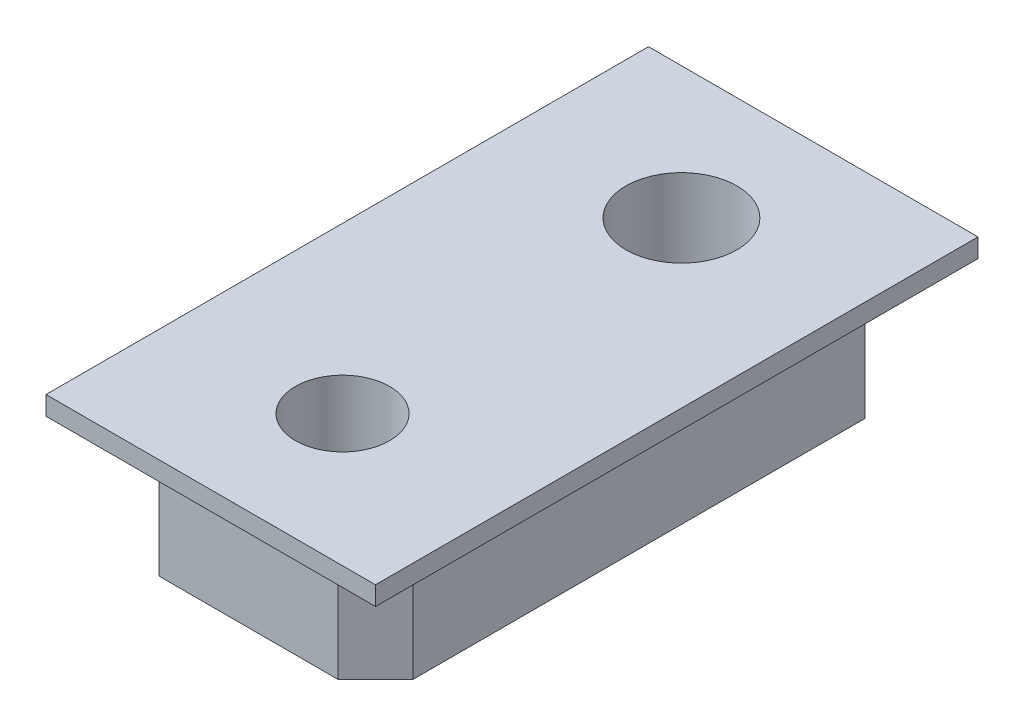
from build123d import *

# Parameters (mm, degrees)
SKETCH1_W             = 6.75
SKETCH1_H             = 3.175
EXTRUDE1_DEPTH        = 7
SKETCH6_W             = 8.75
SKETCH6_H             = 16
EXTRUDE2_DEPTH        = 0.5
F_4_CLEARANCE_HOLE1_D = 2.9464
SKETCH3_R             = 1.25
CUT_EXTRUDE1_DEPTH    = 4.675
CHAMFER1_SIZE         = 1


with BuildPart() as part:
    # Sketch1 → Extrude1 (new body, symmetric)
    with BuildSketch(Plane.XY):
        with Locations((0, 115.5875)):
            Rectangle(SKETCH1_W, SKETCH1_H)
    extrude(amount=EXTRUDE1_DEPTH, both=True)

    # Sketch6 → Extrude2 (add)
    with BuildSketch(Plane(origin=(0, 117.175, 0), x_dir=(1, 0, 0), z_dir=(0, 1, 0))):
        Rectangle(SKETCH6_W, SKETCH6_H)
    extrude(amount=EXTRUDE2_DEPTH)

    # 4 Clearance Hole1 (through all)
    with Locations(Plane(origin=(-0.355703292, 117.675, 3.885176073), x_dir=(-1, 0, 0), z_dir=(0, 1, 0))):
        with Locations((-0.355703292, -8.385176073)):
            Hole(F_4_CLEARANCE_HOLE1_D / 2)

    # Sketch3 → Cut-Extrude1 (cut, through all)
    with BuildSketch(Plane(origin=(0, 117.675, 0), x_dir=(1, 0, 0), z_dir=(0, 1, 0))):
        with Locations(Location((0, -4.5, 0), (0, 0, 270))):  # turned: the seam where the file's is
            Circle(SKETCH3_R)
    extrude(amount=-CUT_EXTRUDE1_DEPTH, mode=Mode.SUBTRACT)

    # Chamfer1
    chamfer1_edges = [part.edges().sort_by_distance(p)[0] for p in [
        (-3.375, 115.5875, 7),
        (-3.375, 115.5875, -7),
        (3.375, 115.5875, -7),
        (3.375, 115.5875, 7),
    ]]
    chamfer(chamfer1_edges, length=CHAMFER1_SIZE)


solid = part.part
